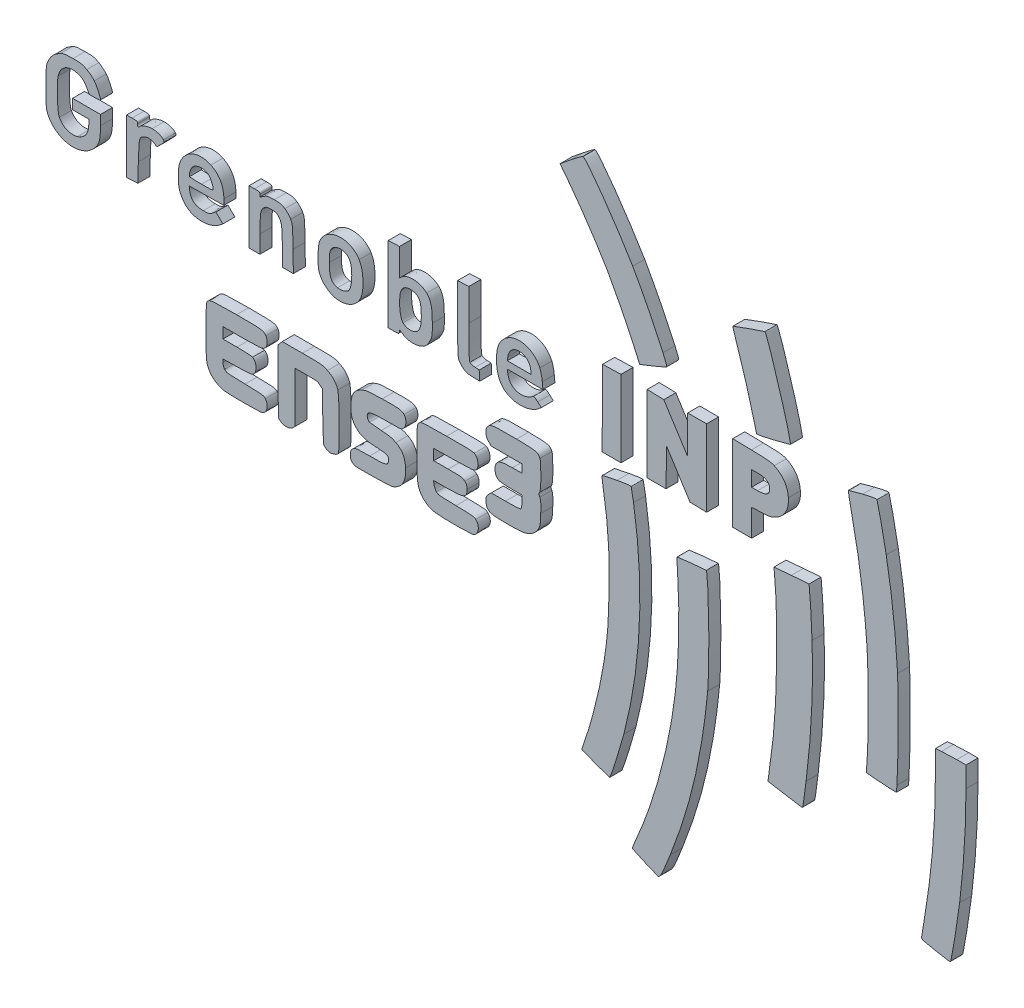
from build123d import *

# Parameters (mm, degrees)
BOSS_EXTRU_1_DEPTH    = 5
BOSS_EXTRU_1_2_DEPTH  = 5
BOSS_EXTRU_1_3_DEPTH  = 5
BOSS_EXTRU_1_4_DEPTH  = 5
BOSS_EXTRU_1_5_DEPTH  = 5
BOSS_EXTRU_1_6_DEPTH  = 5
BOSS_EXTRU_1_7_DEPTH  = 5
BOSS_EXTRU_1_8_DEPTH  = 5
BOSS_EXTRU_1_9_DEPTH  = 5
BOSS_EXTRU_1_10_DEPTH = 5
BOSS_EXTRU_1_11_DEPTH = 5
BOSS_EXTRU_1_12_DEPTH = 5
BOSS_EXTRU_1_13_DEPTH = 5
BOSS_EXTRU_1_14_DEPTH = 5
BOSS_EXTRU_1_15_DEPTH = 5
BOSS_EXTRU_1_16_DEPTH = 5
BOSS_EXTRU_1_17_DEPTH = 5
BOSS_EXTRU_1_18_DEPTH = 5
BOSS_EXTRU_1_19_DEPTH = 5
BOSS_EXTRU_1_20_DEPTH = 5
BOSS_EXTRU_1_21_DEPTH = 5
BOSS_EXTRU_1_22_DEPTH = 5
BOSS_EXTRU_1_23_DEPTH = 5


with BuildPart() as part:
    # Model → Boss.-Extru.1 (new body)
    with BuildSketch(Plane.XY):
        with BuildLine():
            Line((370.498256, 93.602025), (370.500131, 103.7665465))
            Line((370.500131, 103.7665465), (373.031381, 104.005609))
            add(Edge.make_bspline(
                [(373.031381, 104.005609), (374.423569, 104.137091), (377.2923, 104.2458675), (379.4064, 104.247334)],
                knots=[0, 0, 0, 0, 1, 1, 1, 1], degree=3))
            Line((379.4064, 104.247334), (383.25, 104.25))
            Line((383.25, 104.25), (383.25, 95.679979))
            add(Edge.make_bspline(
                [(383.25, 95.679979), (383.25, 81.8276325), (382.3465875, 67.311015), (380.6094, 53.25)],
                knots=[0, 0, 0, 0, 1, 1, 1, 1], degree=3))
            add(Edge.make_bspline(
                [(380.6094, 53.25), (379.78635, 46.5877535), (377.35485, 31.4443765), (376.9404375, 30.399585)],
                knots=[0, 0, 0, 0, 1, 1, 1, 1], degree=3))
            add(Edge.make_bspline(
                [(376.9404375, 30.399585), (376.7071875, 29.8114985), (376.2201375, 29.8524185), (370.6875, 30.9248885)],
                knots=[0, 0, 0, 0, 1, 1, 1, 1], degree=3))
            add(Edge.make_bspline(
                [(370.6875, 30.9248885), (365.301105, 31.969009), (364.694006, 32.1633525), (364.75113, 32.8252275)],
                knots=[0, 0, 0, 0, 1, 1, 1, 1], degree=3))
            add(Edge.make_bspline(
                [(364.75113, 32.8252275), (364.7861175, 33.2307265), (365.32917, 36.6), (365.9579025, 40.3125)],
                knots=[0, 0, 0, 0, 1, 1, 1, 1], degree=3))
            add(Edge.make_bspline(
                [(365.9579025, 40.3125), (369.01626, 58.371394), (370.4951925, 75.7294315), (370.498256, 93.602025)],
                knots=[0, 0, 0, 0, 1, 1, 1, 1], degree=3))
        make_face()
    extrude(amount=BOSS_EXTRU_1_DEPTH)


with BuildPart() as body_2:
    # Model → Boss.-Extru.1 2 (new body)
    with BuildSketch(Plane.XY):
        with BuildLine():
            Line((303.509539, 133.339766), (303.2850525, 135.6170325))
            Line((303.2850525, 135.6170325), (310.51746, 136.2460835))
            add(Edge.make_bspline(
                [(310.51746, 136.2460835), (314.495284, 136.5920585), (317.7958615, 136.8291375), (317.8520775, 136.772921)],
                knots=[0, 0, 0, 0, 1, 1, 1, 1], degree=3))
            add(Edge.make_bspline(
                [(317.8520775, 136.772921), (318.128865, 136.496134), (318.784729, 126.5555435), (319.152645, 117.0609375)],
                knots=[0, 0, 0, 0, 1, 1, 1, 1], degree=3))
            add(Edge.make_bspline(
                [(319.152645, 117.0609375), (319.784509, 100.7548125), (318.9010425, 82.25223), (316.6698115, 65.0625)],
                knots=[0, 0, 0, 0, 1, 1, 1, 1], degree=3))
            add(Edge.make_bspline(
                [(316.6698115, 65.0625), (315.355901, 54.9399375), (315.321499, 54.7451025), (314.8568735, 54.7953865)],
                knots=[0, 0, 0, 0, 1, 1, 1, 1], degree=3))
            add(Edge.make_bspline(
                [(314.8568735, 54.7953865), (314.626219, 54.8203615), (311.4, 55.344049), (307.6875, 55.959169)],
                knots=[0, 0, 0, 0, 1, 1, 1, 1], degree=3))
            add(Edge.make_bspline(
                [(307.6875, 55.959169), (303.975, 56.5742885), (300.891495, 57.1201835), (300.8352675, 57.1722675)],
                knots=[0, 0, 0, 0, 1, 1, 1, 1], degree=3))
            add(Edge.make_bspline(
                [(300.8352675, 57.1722675), (300.779036, 57.2243515), (300.983385, 58.9365865), (301.289374, 60.977235)],
                knots=[0, 0, 0, 0, 1, 1, 1, 1], degree=3))
            add(Edge.make_bspline(
                [(301.289374, 60.977235), (303.427399, 75.23586), (304.1690925, 85.0917485), (304.393369, 102.22419)],
                knots=[0, 0, 0, 0, 1, 1, 1, 1], degree=3))
            add(Edge.make_bspline(
                [(304.393369, 102.22419), (304.571775, 115.85289), (304.30398, 125.280791), (303.509539, 133.339766)],
                knots=[0, 0, 0, 0, 1, 1, 1, 1], degree=3))
        make_face()
    extrude(amount=BOSS_EXTRU_1_2_DEPTH)


with BuildPart() as body_3:
    # Model → Boss.-Extru.1 3 (new body)
    with BuildSketch(Plane.XY):
        with BuildLine():
            Line((354.509865, 82.59375), (354.2903625, 79.875))
            Line((354.2903625, 79.875), (351.9889275, 79.927065))
            add(Edge.make_bspline(
                [(351.9889275, 79.927065), (350.7231415, 79.9556775), (347.9220115, 80.1321225), (345.764194, 80.3191125)],
                knots=[0, 0, 0, 0, 1, 1, 1, 1], degree=3))
            add(Edge.make_bspline(
                [(345.764194, 80.3191125), (343.6063835, 80.5061065), (341.798666, 80.701335), (341.7470435, 80.7529535)],
                knots=[0, 0, 0, 0, 1, 1, 1, 1], degree=3))
            add(Edge.make_bspline(
                [(341.7470435, 80.7529535), (341.695425, 80.8045725), (341.84271, 82.9484625), (342.07434, 85.5171525)],
                knots=[0, 0, 0, 0, 1, 1, 1, 1], degree=3))
            add(Edge.make_bspline(
                [(342.07434, 85.5171525), (342.6552115, 91.9587225), (342.6463125, 118.350101), (342.06069, 126)],
                knots=[0, 0, 0, 0, 1, 1, 1, 1], degree=3))
            add(Edge.make_bspline(
                [(342.06069, 126), (340.7378965, 143.2795725), (338.8815865, 156.224445), (335.4000075, 172.44792)],
                knots=[0, 0, 0, 0, 1, 1, 1, 1], degree=3))
            add(Edge.make_bspline(
                [(335.4000075, 172.44792), (334.6758415, 175.8224025), (334.171054, 178.671056), (334.278259, 178.7782615)],
                knots=[0, 0, 0, 0, 1, 1, 1, 1], degree=3))
            add(Edge.make_bspline(
                [(334.278259, 178.7782615), (334.385464, 178.885466), (337.0526475, 179.608834), (340.2053365, 180.38574)],
                knots=[0, 0, 0, 0, 1, 1, 1, 1], degree=3))
            add(Edge.make_bspline(
                [(340.2053365, 180.38574), (344.3497615, 181.4070375), (346.0068375, 181.6776335), (346.1878425, 181.3626675)],
                knots=[0, 0, 0, 0, 1, 1, 1, 1], degree=3))
            add(Edge.make_bspline(
                [(346.1878425, 181.3626675), (346.51092, 180.8004785), (348.8174815, 170.051441), (350.042719, 163.3981575)],
                knots=[0, 0, 0, 0, 1, 1, 1, 1], degree=3))
            add(Edge.make_bspline(
                [(350.042719, 163.3981575), (352.2835725, 151.2299175), (353.9911465, 136.670906), (354.780874, 123)],
                knots=[0, 0, 0, 0, 1, 1, 1, 1], degree=3))
            add(Edge.make_bspline(
                [(354.780874, 123), (355.2110515, 115.553216), (355.033489, 89.0793185), (354.509865, 82.59375)],
                knots=[0, 0, 0, 0, 1, 1, 1, 1], degree=3))
        make_face()
    extrude(amount=BOSS_EXTRU_1_3_DEPTH)


with BuildPart() as body_4:
    # Model → Boss.-Extru.1 4 (new body)
    with BuildSketch(Plane.XY):
        with BuildLine():
            Line((81.7746525, 107.625), (73.875, 107.625))
            Line((73.875, 107.625), (73.875, 105.375))
            Line((73.875, 105.375), (73.875, 103.125))
            Line((73.875, 103.125), (79.7121525, 103.125))
            add(Edge.make_bspline(
                [(79.7121525, 103.125), (82.9225875, 103.125), (85.8525675, 102.9627), (86.2232215, 102.7643325)],
                knots=[0, 0, 0, 0, 1, 1, 1, 1], degree=3))
            add(Edge.make_bspline(
                [(86.2232215, 102.7643325), (87.915454, 101.8586775), (88.131154, 98.301259), (86.579089, 96.8952335)],
                knots=[0, 0, 0, 0, 1, 1, 1, 1], degree=3))
            add(Edge.make_bspline(
                [(86.579089, 96.8952335), (85.896619, 96.276979), (85.04415, 96.17148), (79.8364235, 96.0608025)],
                knots=[0, 0, 0, 0, 1, 1, 1, 1], degree=3))
            Line((79.8364235, 96.0608025), (73.875, 95.934105))
            Line((73.875, 95.934105), (73.875, 94.6960985))
            add(Edge.make_bspline(
                [(73.875, 94.6960985), (73.875, 94.0151925), (74.197346, 93.0597075), (74.591325, 92.5727925)],
                knots=[0, 0, 0, 0, 1, 1, 1, 1], degree=3))
            add(Edge.make_bspline(
                [(74.591325, 92.5727925), (75.292504, 91.706216), (75.4715925, 91.683536), (83.0629875, 91.5)],
                knots=[0, 0, 0, 0, 1, 1, 1, 1], degree=3))
            add(Edge.make_bspline(
                [(83.0629875, 91.5), (90.654559, 91.31646), (90.833441, 91.293806), (91.5341625, 90.4272075)],
                knots=[0, 0, 0, 0, 1, 1, 1, 1], degree=3))
            add(Edge.make_bspline(
                [(91.5341625, 90.4272075), (92.6248085, 89.0783775), (92.5000575, 86.615854), (91.283115, 85.4716165)],
                knots=[0, 0, 0, 0, 1, 1, 1, 1], degree=3))
            add(Edge.make_bspline(
                [(91.283115, 85.4716165), (90.335025, 84.580174), (90.176475, 84.5612065), (83.126865, 84.4958965)],
                knots=[0, 0, 0, 0, 1, 1, 1, 1], degree=3))
            add(Edge.make_bspline(
                [(83.126865, 84.4958965), (79.172715, 84.459259), (75.236134, 84.5743275), (74.3789065, 84.75159)],
                knots=[0, 0, 0, 0, 1, 1, 1, 1], degree=3))
            add(Edge.make_bspline(
                [(74.3789065, 84.75159), (70.5248215, 85.5485625), (67.909789, 88.0040065), (67.152, 91.5374475)],
                knots=[0, 0, 0, 0, 1, 1, 1, 1], degree=3))
            add(Edge.make_bspline(
                [(67.152, 91.5374475), (66.6060485, 94.083135), (66.617891, 111.7997665), (67.1663625, 113.003505)],
                knots=[0, 0, 0, 0, 1, 1, 1, 1], degree=3))
            add(Edge.make_bspline(
                [(67.1663625, 113.003505), (67.9040775, 114.6226125), (68.8067625, 114.75), (79.5423075, 114.75)],
                knots=[0, 0, 0, 0, 1, 1, 1, 1], degree=3))
            add(Edge.make_bspline(
                [(79.5423075, 114.75), (89.838064, 114.75), (90.7242865, 114.643635), (91.7693365, 113.2824975)],
                knots=[0, 0, 0, 0, 1, 1, 1, 1], degree=3))
            add(Edge.make_bspline(
                [(91.7693365, 113.2824975), (92.359275, 112.5141225), (92.359275, 109.8608775), (91.7693365, 109.0925025)],
                knots=[0, 0, 0, 0, 1, 1, 1, 1], degree=3))
            add(Edge.make_bspline(
                [(91.7693365, 109.0925025), (90.753896, 107.7699485), (89.7667125, 107.625), (81.7746525, 107.625)],
                knots=[0, 0, 0, 0, 1, 1, 1, 1], degree=3))
        make_face()
    extrude(amount=BOSS_EXTRU_1_4_DEPTH)


with BuildPart() as body_5:
    # Model → Boss.-Extru.1 5 (new body)
    with BuildSketch(Plane.XY):
        with BuildLine():
            Line((115.4135365, 96.501731), (115.3125, 105.8159625))
            Line((115.3125, 105.8159625), (114.26034, 106.720481))
            add(Edge.make_bspline(
                [(114.26034, 106.720481), (113.2701975, 107.5716825), (112.9330985, 107.625), (108.54159, 107.625)],
                knots=[0, 0, 0, 0, 1, 1, 1, 1], degree=3))
            Line((108.54159, 107.625), (103.875, 107.625))
            Line((103.875, 107.625), (103.875, 97.1079565))
            Line((103.875, 97.1079565), (103.875, 86.5909085))
            Line((103.875, 86.5909085), (102.9545435, 85.6704565))
            add(Edge.make_bspline(
                [(102.9545435, 85.6704565), (101.778476, 84.494385), (99.152835, 84.390041), (97.8227925, 85.46652)],
                knots=[0, 0, 0, 0, 1, 1, 1, 1], degree=3))
            Line((97.8227925, 85.46652), (96.9375, 86.183036))
            Line((96.9375, 86.183036), (96.830025, 99.3046535))
            Line((96.830025, 99.3046535), (96.722554, 112.4262675))
            Line((96.722554, 112.4262675), (97.641915, 113.4943835))
            Line((97.641915, 113.4943835), (98.56128, 114.5625))
            Line((98.56128, 114.5625), (106.93689, 114.5625))
            add(Edge.make_bspline(
                [(106.93689, 114.5625), (115.2932965, 114.5625), (115.3172625, 114.56025), (117.39021, 113.542095)],
                knots=[0, 0, 0, 0, 1, 1, 1, 1], degree=3))
            add(Edge.make_bspline(
                [(117.39021, 113.542095), (119.6543325, 112.4301415), (120.871744, 111.062096), (121.70907, 108.68886)],
                knots=[0, 0, 0, 0, 1, 1, 1, 1], degree=3))
            add(Edge.make_bspline(
                [(121.70907, 108.68886), (122.365399, 106.8286315), (122.5053565, 87.05283), (121.8705865, 85.866754)],
                knots=[0, 0, 0, 0, 1, 1, 1, 1], degree=3))
            add(Edge.make_bspline(
                [(121.8705865, 85.866754), (121.66191, 85.47684), (120.8603475, 84.982624), (120.0893365, 84.768499)],
                knots=[0, 0, 0, 0, 1, 1, 1, 1], degree=3))
            add(Edge.make_bspline(
                [(120.0893365, 84.768499), (118.393335, 84.2974875), (118.5815215, 84.287389), (117.106819, 84.9285825)],
                knots=[0, 0, 0, 0, 1, 1, 1, 1], degree=3))
            add(Edge.make_bspline(
                [(117.106819, 84.9285825), (116.389864, 85.2403085), (115.822785, 85.804391), (115.7078515, 86.320151)],
                knots=[0, 0, 0, 0, 1, 1, 1, 1], degree=3))
            add(Edge.make_bspline(
                [(115.7078515, 86.320151), (115.6015465, 86.7971925), (115.469104, 91.378905), (115.4135365, 96.501731)],
                knots=[0, 0, 0, 0, 1, 1, 1, 1], degree=3))
        make_face()
    extrude(amount=BOSS_EXTRU_1_5_DEPTH)


with BuildPart() as body_6:
    # Model → Boss.-Extru.1 6 (new body)
    with BuildSketch(Plane.XY):
        with BuildLine():
            Line((170.0498665, 107.6988075), (161.625, 107.5851185))
            Line((161.625, 107.5851185), (161.625, 105.3550575))
            Line((161.625, 105.3550575), (161.625, 103.125))
            Line((161.625, 103.125), (167.6420435, 103.125))
            add(Edge.make_bspline(
                [(167.6420435, 103.125), (173.530515, 103.125), (173.67876, 103.1053125), (174.5795435, 102.2045435)],
                knots=[0, 0, 0, 0, 1, 1, 1, 1], degree=3))
            add(Edge.make_bspline(
                [(174.5795435, 102.2045435), (175.276879, 101.5072125), (175.4971085, 100.89363), (175.488075, 99.6732935)],
                knots=[0, 0, 0, 0, 1, 1, 1, 1], degree=3))
            add(Edge.make_bspline(
                [(175.488075, 99.6732935), (175.4646525, 96.509805), (174.249791, 96), (166.73466, 96)],
                knots=[0, 0, 0, 0, 1, 1, 1, 1], degree=3))
            Line((166.73466, 96), (161.52687, 96))
            Line((161.52687, 96), (161.751435, 94.6161675))
            add(Edge.make_bspline(
                [(161.751435, 94.6161675), (161.874945, 93.85506), (162.32319, 92.8847475), (162.747536, 92.4599175)],
                knots=[0, 0, 0, 0, 1, 1, 1, 1], degree=3))
            add(Edge.make_bspline(
                [(162.747536, 92.4599175), (163.465571, 91.7410615), (164.0319935, 91.679404), (170.915786, 91.570729)],
                knots=[0, 0, 0, 0, 1, 1, 1, 1], degree=3))
            add(Edge.make_bspline(
                [(170.915786, 91.570729), (177.7166775, 91.4633665), (178.3771125, 91.3932825), (179.114629, 90.7007135)],
                knots=[0, 0, 0, 0, 1, 1, 1, 1], degree=3))
            add(Edge.make_bspline(
                [(179.114629, 90.7007135), (180.9302925, 88.9956975), (180.3485475, 85.5813225), (178.1093815, 84.800745)],
                knots=[0, 0, 0, 0, 1, 1, 1, 1], degree=3))
            add(Edge.make_bspline(
                [(178.1093815, 84.800745), (176.7309935, 84.3202385), (165.1078685, 84.2863875), (162.33861, 84.754815)],
                knots=[0, 0, 0, 0, 1, 1, 1, 1], degree=3))
            add(Edge.make_bspline(
                [(162.33861, 84.754815), (160.228335, 85.1117735), (158.7548325, 85.8474415), (157.363635, 87.238635)],
                knots=[0, 0, 0, 0, 1, 1, 1, 1], degree=3))
            add(Edge.make_bspline(
                [(157.363635, 87.238635), (154.8526725, 89.7496015), (154.4226525, 92.3258585), (154.5727275, 103.959056)],
                knots=[0, 0, 0, 0, 1, 1, 1, 1], degree=3))
            add(Edge.make_bspline(
                [(154.5727275, 103.959056), (154.6847325, 112.6409475), (154.708095, 112.876204), (155.541101, 113.709056)],
                knots=[0, 0, 0, 0, 1, 1, 1, 1], degree=3))
            add(Edge.make_bspline(
                [(155.541101, 113.709056), (156.383854, 114.551655), (156.529189, 114.5637335), (166.978601, 114.659614)],
                knots=[0, 0, 0, 0, 1, 1, 1, 1], degree=3))
            add(Edge.make_bspline(
                [(166.978601, 114.659614), (175.02201, 114.733421), (177.78753, 114.641051), (178.5, 114.2748375)],
                knots=[0, 0, 0, 0, 1, 1, 1, 1], degree=3))
            add(Edge.make_bspline(
                [(178.5, 114.2748375), (179.678089, 113.669276), (180.392265, 111.6177525), (179.9553375, 110.094266)],
                knots=[0, 0, 0, 0, 1, 1, 1, 1], degree=3))
            add(Edge.make_bspline(
                [(179.9553375, 110.094266), (179.307761, 107.836309), (179.2527185, 107.823), (170.0498665, 107.6988075)],
                knots=[0, 0, 0, 0, 1, 1, 1, 1], degree=3))
        make_face()
    extrude(amount=BOSS_EXTRU_1_6_DEPTH)


with BuildPart() as body_7:
    # Model → Boss.-Extru.1 7 (new body)
    with BuildSketch(Plane.XY):
        with BuildLine():
            Line((184.471155, 102.403845), (185.5673065, 103.5))
            Line((185.5673065, 103.5), (191.521155, 103.5))
            add(Edge.make_bspline(
                [(191.521155, 103.5), (195.6519225, 103.5), (197.61279, 103.63779), (197.925, 103.95)],
                knots=[0, 0, 0, 0, 1, 1, 1, 1], degree=3))
            add(Edge.make_bspline(
                [(197.925, 103.95), (198.179764, 104.2047635), (198.375, 105.4249985), (198.375, 106.7625)],
                knots=[0, 0, 0, 0, 1, 1, 1, 1], degree=3))
            Line((198.375, 106.7625), (198.375, 109.125))
            Line((198.375, 109.125), (194.080144, 109.125))
            add(Edge.make_bspline(
                [(194.080144, 109.125), (191.717974, 109.125), (189.3740815, 109.3123575), (188.871495, 109.541351)],
                knots=[0, 0, 0, 0, 1, 1, 1, 1], degree=3))
            add(Edge.make_bspline(
                [(188.871495, 109.541351), (187.269225, 110.271394), (186.62838, 112.874745), (187.55196, 114.901785)],
                knots=[0, 0, 0, 0, 1, 1, 1, 1], degree=3))
            add(Edge.make_bspline(
                [(187.55196, 114.901785), (188.2703475, 116.4784725), (189.972581, 117), (194.4004235, 117)],
                knots=[0, 0, 0, 0, 1, 1, 1, 1], degree=3))
            Line((194.4004235, 117), (198.375, 117))
            Line((198.375, 117), (198.375, 118.6875))
            Line((198.375, 118.6875), (198.375, 120.375))
            Line((198.375, 120.375), (191.971155, 120.375))
            Line((191.971155, 120.375), (185.5673065, 120.375))
            Line((185.5673065, 120.375), (184.471155, 121.471155))
            add(Edge.make_bspline(
                [(184.471155, 121.471155), (183.00801, 122.9343), (182.9086575, 125.567749), (184.265415, 126.9245065)],
                knots=[0, 0, 0, 0, 1, 1, 1, 1], degree=3))
            add(Edge.make_bspline(
                [(184.265415, 126.9245065), (185.490364, 128.149455), (187.1674765, 128.3276815), (196.12623, 128.184956)],
                knots=[0, 0, 0, 0, 1, 1, 1, 1], degree=3))
            add(Edge.make_bspline(
                [(196.12623, 128.184956), (204.33114, 128.0542385), (205.02405, 127.905375), (205.848315, 126.096315)],
                knots=[0, 0, 0, 0, 1, 1, 1, 1], degree=3))
            add(Edge.make_bspline(
                [(205.848315, 126.096315), (206.459209, 124.7555435), (206.3741475, 114.688129), (205.7446465, 113.827234)],
                knots=[0, 0, 0, 0, 1, 1, 1, 1], degree=3))
            add(Edge.make_bspline(
                [(205.7446465, 113.827234), (205.318654, 113.2446525), (205.3255875, 112.963144), (205.7888025, 112.034606)],
                knots=[0, 0, 0, 0, 1, 1, 1, 1], degree=3))
            add(Edge.make_bspline(
                [(205.7888025, 112.034606), (206.2100775, 111.19014), (206.3028825, 109.8688875), (206.1864825, 106.3727925)],
                knots=[0, 0, 0, 0, 1, 1, 1, 1], degree=3))
            add(Edge.make_bspline(
                [(206.1864825, 106.3727925), (206.0541115, 102.3969525), (205.9162875, 101.598364), (205.1110765, 100.14165)],
                knots=[0, 0, 0, 0, 1, 1, 1, 1], degree=3))
            add(Edge.make_bspline(
                [(205.1110765, 100.14165), (203.934034, 98.012254), (201.7385365, 96.4833335), (199.167566, 96.002655)],
                knots=[0, 0, 0, 0, 1, 1, 1, 1], degree=3))
            add(Edge.make_bspline(
                [(199.167566, 96.002655), (196.110686, 95.4311285), (186.813825, 95.545031), (185.3732775, 96.17166)],
                knots=[0, 0, 0, 0, 1, 1, 1, 1], degree=3))
            add(Edge.make_bspline(
                [(185.3732775, 96.17166), (183.8985115, 96.8131725), (183.375, 97.751726), (183.375, 99.7541925)],
                knots=[0, 0, 0, 0, 1, 1, 1, 1], degree=3))
            add(Edge.make_bspline(
                [(183.375, 99.7541925), (183.375, 100.9712175), (183.612416, 101.54511), (184.471155, 102.403845)],
                knots=[0, 0, 0, 0, 1, 1, 1, 1], degree=3))
        make_face()
    extrude(amount=BOSS_EXTRU_1_7_DEPTH)


with BuildPart() as body_8:
    # Model → Boss.-Extru.1 8 (new body)
    with BuildSketch(Plane.XY):
        with BuildLine():
            Line((20.53125, 163.5010835), (18.1875, 163.5022085))
            Line((18.1875, 163.5022085), (17.25, 165.2558025))
            add(Edge.make_bspline(
                [(17.25, 165.2558025), (16.129121, 167.352405), (14.9273015, 168.30258), (12.7884755, 168.7831425)],
                knots=[0, 0, 0, 0, 1, 1, 1, 1], degree=3))
            add(Edge.make_bspline(
                [(12.7884755, 168.7831425), (9.150577, 169.600526), (6.0431255, 167.508004), (5.254654, 163.709955)],
                knots=[0, 0, 0, 0, 1, 1, 1, 1], degree=3))
            add(Edge.make_bspline(
                [(5.254654, 163.709955), (4.5797245, 160.458836), (4.893112, 150.558641), (5.719867, 149.0134575)],
                knots=[0, 0, 0, 0, 1, 1, 1, 1], degree=3))
            add(Edge.make_bspline(
                [(5.719867, 149.0134575), (7.199301, 146.248429), (10.1992055, 145.0033685), (13.2941165, 145.8698885)],
                knots=[0, 0, 0, 0, 1, 1, 1, 1], degree=3))
            add(Edge.make_bspline(
                [(13.2941165, 145.8698885), (16.305325, 146.7129375), (18, 149.141254), (18, 152.612955)],
                knots=[0, 0, 0, 0, 1, 1, 1, 1], degree=3))
            Line((18, 152.612955), (18, 154.5))
            Line((18, 154.5), (14.625, 154.5))
            Line((14.625, 154.5), (11.25, 154.5))
            Line((11.25, 154.5), (11.25, 156.5625))
            Line((11.25, 156.5625), (11.25, 158.625))
            Line((11.25, 158.625), (17.0625, 158.625))
            Line((17.0625, 158.625), (22.875, 158.625))
            Line((22.875, 158.625), (22.875, 154.5680625))
            add(Edge.make_bspline(
                [(22.875, 154.5680625), (22.875, 149.04867), (22.2594395, 147.085526), (19.7382505, 144.5643375)],
                knots=[0, 0, 0, 0, 1, 1, 1, 1], degree=3))
            add(Edge.make_bspline(
                [(19.7382505, 144.5643375), (16.9865475, 141.812636), (12.8876685, 140.58441), (9.1002035, 141.3766615)],
                knots=[0, 0, 0, 0, 1, 1, 1, 1], degree=3))
            add(Edge.make_bspline(
                [(9.1002035, 141.3766615), (5.47001, 142.1360135), (2.4535505, 144.4224265), (1.084447, 147.4524375)],
                knots=[0, 0, 0, 0, 1, 1, 1, 1], degree=3))
            add(Edge.make_bspline(
                [(1.084447, 147.4524375), (0.23001, 149.34342), (0.1875, 149.81073), (0.1875, 157.3125)],
                knots=[0, 0, 0, 0, 1, 1, 1, 1], degree=3))
            add(Edge.make_bspline(
                [(0.1875, 157.3125), (0.1875, 165.179134), (0.188616, 165.1897725), (1.2379085, 167.3265375)],
                knots=[0, 0, 0, 0, 1, 1, 1, 1], degree=3))
            add(Edge.make_bspline(
                [(1.2379085, 167.3265375), (2.357268, 169.6059825), (3.6558345, 170.905665), (6.143824, 172.236675)],
                knots=[0, 0, 0, 0, 1, 1, 1, 1], degree=3))
            add(Edge.make_bspline(
                [(6.143824, 172.236675), (7.439466, 172.92981), (8.2900405, 173.0625), (11.4375, 173.0625)],
                knots=[0, 0, 0, 0, 1, 1, 1, 1], degree=3))
            add(Edge.make_bspline(
                [(11.4375, 173.0625), (14.888436, 173.0625), (15.346708, 172.9743075), (17.183831, 171.95664)],
                knots=[0, 0, 0, 0, 1, 1, 1, 1], degree=3))
            add(Edge.make_bspline(
                [(17.183831, 171.95664), (18.281813, 171.3484165), (19.6920875, 170.2044225), (20.317774, 169.414429)],
                knots=[0, 0, 0, 0, 1, 1, 1, 1], degree=3))
            add(Edge.make_bspline(
                [(20.317774, 169.414429), (21.34657, 168.115466), (22.875, 164.802199), (22.875, 163.870976)],
                knots=[0, 0, 0, 0, 1, 1, 1, 1], degree=3))
            add(Edge.make_bspline(
                [(22.875, 163.870976), (22.875, 163.665795), (21.8275395, 163.500484), (20.53125, 163.5010835)],
                knots=[0, 0, 0, 0, 1, 1, 1, 1], degree=3))
        make_face()
    extrude(amount=BOSS_EXTRU_1_8_DEPTH)


with BuildPart() as body_9:
    # Model → Boss.-Extru.1 9 (new body)
    with BuildSketch(Plane.XY):
        with BuildLine():
            Line((74.25, 153.8787935), (74.25, 151.5161965))
            Line((74.25, 151.5161965), (67.03125, 151.414346))
            Line((67.03125, 151.414346), (59.8125, 151.3125))
            Line((59.8125, 151.3125), (59.939824, 150.1875))
            add(Edge.make_bspline(
                [(59.939824, 150.1875), (60.3202615, 146.8260865), (62.07813, 145.32843), (65.65419, 145.3190025)],
                knots=[0, 0, 0, 0, 1, 1, 1, 1], degree=3))
            add(Edge.make_bspline(
                [(65.65419, 145.3190025), (67.7973485, 145.31334), (68.3057965, 145.4535415), (69.5307265, 146.3878425)],
                knots=[0, 0, 0, 0, 1, 1, 1, 1], degree=3))
            Line((69.5307265, 146.3878425), (70.9405725, 147.463181))
            Line((70.9405725, 147.463181), (72.3883575, 146.0494575))
            Line((72.3883575, 146.0494575), (73.8361465, 144.63573))
            Line((73.8361465, 144.63573), (72.305974, 143.4248625))
            add(Edge.make_bspline(
                [(72.305974, 143.4248625), (69.932434, 141.5466115), (65.9642025, 140.703664), (62.69409, 141.383066)],
                knots=[0, 0, 0, 0, 1, 1, 1, 1], degree=3))
            add(Edge.make_bspline(
                [(62.69409, 141.383066), (59.669644, 142.011439), (57.574125, 143.7617775), (56.1883425, 146.81718)],
                knots=[0, 0, 0, 0, 1, 1, 1, 1], degree=3))
            add(Edge.make_bspline(
                [(56.1883425, 146.81718), (55.4787415, 148.381725), (55.340685, 149.331259), (55.3439215, 152.6250075)],
                knots=[0, 0, 0, 0, 1, 1, 1, 1], degree=3))
            add(Edge.make_bspline(
                [(55.3439215, 152.6250075), (55.347296, 155.922079), (55.4890615, 156.8813215), (56.21637, 158.5226515)],
                knots=[0, 0, 0, 0, 1, 1, 1, 1], degree=3))
            add(Edge.make_bspline(
                [(56.21637, 158.5226515), (58.438054, 163.5363565), (63.9339035, 165.641295), (68.8390725, 163.357219)],
                knots=[0, 0, 0, 0, 1, 1, 1, 1], degree=3))
            add(Edge.make_bspline(
                [(68.8390725, 163.357219), (72.3173625, 161.7375565), (74.25, 158.352124), (74.25, 153.8787935)],
                knots=[0, 0, 0, 0, 1, 1, 1, 1], degree=3))
        make_face()
        with BuildLine():
            add(Edge.make_bspline(
                [(69.75, 155.24241), (69.75, 156.520515), (68.598896, 158.9308465), (67.7105285, 159.512929)],
                knots=[0, 0, 0, 0, 1, 1, 1, 1], degree=3))
            add(Edge.make_bspline(
                [(67.7105285, 159.512929), (65.511004, 160.95411), (62.2229475, 160.451966), (60.929085, 158.4772875)],
                knots=[0, 0, 0, 0, 1, 1, 1, 1], degree=3))
            add(Edge.make_bspline(
                [(60.929085, 158.4772875), (60.2343675, 157.417016), (59.5948575, 155.030141), (59.918726, 154.7062725)],
                knots=[0, 0, 0, 0, 1, 1, 1, 1], degree=3))
            add(Edge.make_bspline(
                [(59.918726, 154.7062725), (60.032175, 154.592824), (62.2906235, 154.5), (64.937501, 154.5)],
                knots=[0, 0, 0, 0, 1, 1, 1, 1], degree=3))
            add(Edge.make_bspline(
                [(64.937501, 154.5), (69.483604, 154.5), (69.75, 154.5410965), (69.75, 155.24241)],
                knots=[0, 0, 0, 0, 1, 1, 1, 1], degree=3))
        make_face(mode=Mode.SUBTRACT)
    extrude(amount=BOSS_EXTRU_1_9_DEPTH)


with BuildPart() as body_10:
    # Model → Boss.-Extru.1 10 (new body)
    with BuildSketch(Plane.XY):
        with BuildLine():
            Line((148.4879025, 142.5086135), (147.4288315, 143.262739))
            Line((147.4288315, 143.262739), (147.3081675, 142.4126175))
            add(Edge.make_bspline(
                [(147.3081675, 142.4126175), (147.198075, 141.6369935), (146.9903435, 141.5625), (144.9375, 141.5625)],
                knots=[0, 0, 0, 0, 1, 1, 1, 1], degree=3))
            Line((144.9375, 141.5625), (142.6875, 141.5625))
            Line((142.6875, 141.5625), (142.6875, 157.3125))
            Line((142.6875, 157.3125), (142.6875, 173.0625))
            Line((142.6875, 173.0625), (145.03125, 173.174145))
            Line((145.03125, 173.174145), (147.375, 173.2857865))
            Line((147.375, 173.2857865), (147.375, 167.577525))
            Line((147.375, 167.577525), (147.375, 161.869264))
            Line((147.375, 161.869264), (148.21875, 162.659651))
            add(Edge.make_bspline(
                [(148.21875, 162.659651), (150.7447615, 165.025909), (155.9475075, 164.7518325), (158.7087265, 162.107051)],
                knots=[0, 0, 0, 0, 1, 1, 1, 1], degree=3))
            add(Edge.make_bspline(
                [(158.7087265, 162.107051), (160.455851, 160.4336025), (161.0625, 157.9414165), (161.0625, 152.4375)],
                knots=[0, 0, 0, 0, 1, 1, 1, 1], degree=3))
            add(Edge.make_bspline(
                [(161.0625, 152.4375), (161.0625, 147.770835), (161.014421, 147.466346), (159.9375, 145.3125)],
                knots=[0, 0, 0, 0, 1, 1, 1, 1], degree=3))
            add(Edge.make_bspline(
                [(159.9375, 145.3125), (159.087544, 143.612591), (158.4457725, 142.863829), (157.3125, 142.24989)],
                knots=[0, 0, 0, 0, 1, 1, 1, 1], degree=3))
            add(Edge.make_bspline(
                [(157.3125, 142.24989), (155.4959585, 141.265796), (152.9452425, 140.923181), (150.992235, 141.4009385)],
                knots=[0, 0, 0, 0, 1, 1, 1, 1], degree=3))
            add(Edge.make_bspline(
                [(150.992235, 141.4009385), (150.19734, 141.595395), (149.07039, 142.093849), (148.4879025, 142.5086135)],
                knots=[0, 0, 0, 0, 1, 1, 1, 1], degree=3))
        make_face()
        with BuildLine():
            add(Edge.make_bspline(
                [(154.7703675, 146.355495), (155.9794275, 147.451215), (156.45, 149.2602335), (156.45, 152.8125)],
                knots=[0, 0, 0, 0, 1, 1, 1, 1], degree=3))
            add(Edge.make_bspline(
                [(156.45, 152.8125), (156.45, 157.871115), (155.5230785, 159.6338475), (152.661184, 160.017705)],
                knots=[0, 0, 0, 0, 1, 1, 1, 1], degree=3))
            add(Edge.make_bspline(
                [(152.661184, 160.017705), (150.668074, 160.2850385), (148.99149, 159.5605085), (148.2314965, 158.103431)],
                knots=[0, 0, 0, 0, 1, 1, 1, 1], degree=3))
            add(Edge.make_bspline(
                [(148.2314965, 158.103431), (146.878294, 155.509039), (147.2850715, 147.8763635), (148.852121, 146.4582075)],
                knots=[0, 0, 0, 0, 1, 1, 1, 1], degree=3))
            add(Edge.make_bspline(
                [(148.852121, 146.4582075), (150.4218375, 145.0376325), (153.2617985, 144.9883465), (154.7703675, 146.355495)],
                knots=[0, 0, 0, 0, 1, 1, 1, 1], degree=3))
        make_face(mode=Mode.SUBTRACT)
    extrude(amount=BOSS_EXTRU_1_10_DEPTH)


with BuildPart() as body_11:
    # Model → Boss.-Extru.1 11 (new body)
    with BuildSketch(Plane.XY):
        with BuildLine():
            Line((206.8299485, 154.21875), (207.0969075, 151.5))
            Line((207.0969075, 151.5), (199.6865775, 151.5))
            Line((199.6865775, 151.5), (192.2762475, 151.5))
            Line((192.2762475, 151.5), (192.4856585, 149.9387175))
            add(Edge.make_bspline(
                [(192.4856585, 149.9387175), (193.1108285, 145.277745), (198.37752, 143.643709), (202.6875, 146.7735115)],
                knots=[0, 0, 0, 0, 1, 1, 1, 1], degree=3))
            add(Edge.make_bspline(
                [(202.6875, 146.7735115), (203.37345, 147.2716315), (203.5656, 147.205796), (204.9375, 146.0026425)],
                knots=[0, 0, 0, 0, 1, 1, 1, 1], degree=3))
            Line((204.9375, 146.0026425), (206.4375, 144.6871425))
            Line((206.4375, 144.6871425), (205.3125, 143.7470025))
            add(Edge.make_bspline(
                [(205.3125, 143.7470025), (202.83063, 141.67296), (198.822761, 140.711891), (195.4752035, 141.388069)],
                knots=[0, 0, 0, 0, 1, 1, 1, 1], degree=3))
            add(Edge.make_bspline(
                [(195.4752035, 141.388069), (190.2019275, 142.4532225), (187.7662125, 146.0664375), (187.7636435, 152.8276315)],
                knots=[0, 0, 0, 0, 1, 1, 1, 1], degree=3))
            add(Edge.make_bspline(
                [(187.7636435, 152.8276315), (187.7621435, 156.942926), (188.6258775, 159.4136815), (190.8352575, 161.6134915)],
                knots=[0, 0, 0, 0, 1, 1, 1, 1], degree=3))
            add(Edge.make_bspline(
                [(190.8352575, 161.6134915), (195.437951, 166.1962615), (203.2456985, 164.660186), (205.82082, 158.665275)],
                knots=[0, 0, 0, 0, 1, 1, 1, 1], degree=3))
            add(Edge.make_bspline(
                [(205.82082, 158.665275), (206.229011, 157.714999), (206.6831175, 155.7140625), (206.8299485, 154.21875)],
                knots=[0, 0, 0, 0, 1, 1, 1, 1], degree=3))
        make_face()
        with BuildLine():
            Line((192.4856585, 156.0612825), (192.2762475, 154.5))
            Line((192.2762475, 154.5), (197.25, 154.5))
            Line((197.25, 154.5), (202.2237525, 154.5))
            Line((202.2237525, 154.5), (202.014341, 156.0612825))
            add(Edge.make_bspline(
                [(202.014341, 156.0612825), (201.7354875, 158.1402785), (200.704241, 159.444285), (198.8097785, 160.113439)],
                knots=[0, 0, 0, 0, 1, 1, 1, 1], degree=3))
            add(Edge.make_bspline(
                [(198.8097785, 160.113439), (195.807041, 161.1740475), (192.9236175, 159.326505), (192.4856585, 156.0612825)],
                knots=[0, 0, 0, 0, 1, 1, 1, 1], degree=3))
        make_face(mode=Mode.SUBTRACT)
    extrude(amount=BOSS_EXTRU_1_11_DEPTH)


with BuildPart() as body_12:
    # Model → Boss.-Extru.1 12 (new body)
    with BuildSketch(Plane.XY):
        with BuildLine():
            Line((33.75, 152.607105), (33.75, 163.875))
            Line((33.75, 163.875), (36, 163.875))
            add(Edge.make_bspline(
                [(36, 163.875), (38.1499985, 163.875), (38.25, 163.833334), (38.25, 162.9375)],
                knots=[0, 0, 0, 0, 1, 1, 1, 1], degree=3))
            add(Edge.make_bspline(
                [(38.25, 162.9375), (38.25, 161.9680615), (38.7633115, 161.6886485), (39.2116315, 162.414049)],
                knots=[0, 0, 0, 0, 1, 1, 1, 1], degree=3))
            add(Edge.make_bspline(
                [(39.2116315, 162.414049), (39.7049515, 163.212255), (42.5795775, 164.233609), (44.355795, 164.241765)],
                knots=[0, 0, 0, 0, 1, 1, 1, 1], degree=3))
            add(Edge.make_bspline(
                [(44.355795, 164.241765), (46.3420015, 164.2508775), (48.2818275, 163.579609), (49.0919025, 162.602835)],
                knots=[0, 0, 0, 0, 1, 1, 1, 1], degree=3))
            add(Edge.make_bspline(
                [(49.0919025, 162.602835), (49.563274, 162.0344625), (49.4452465, 161.785099), (48.0151465, 160.3279315)],
                knots=[0, 0, 0, 0, 1, 1, 1, 1], degree=3))
            Line((48.0151465, 160.3279315), (46.4089835, 158.691375))
            Line((46.4089835, 158.691375), (45.2357435, 159.406785))
            add(Edge.make_bspline(
                [(45.2357435, 159.406785), (43.8208015, 160.2695775), (42.3417525, 160.3209865), (40.8674925, 159.5586185)],
                knots=[0, 0, 0, 0, 1, 1, 1, 1], degree=3))
            add(Edge.make_bspline(
                [(40.8674925, 159.5586185), (38.9703825, 158.577585), (38.8272375, 157.9315315), (38.625, 149.4375)],
                knots=[0, 0, 0, 0, 1, 1, 1, 1], degree=3))
            Line((38.625, 149.4375), (38.4375, 141.5625))
            Line((38.4375, 141.5625), (36.09375, 141.450855))
            Line((36.09375, 141.450855), (33.75, 141.3392135))
            Line((33.75, 141.3392135), (33.75, 152.607105))
        make_face()
    extrude(amount=BOSS_EXTRU_1_12_DEPTH)


with BuildPart() as body_13:
    # Model → Boss.-Extru.1 13 (new body)
    with BuildSketch(Plane.XY):
        with BuildLine():
            Line((84.75, 152.625), (84.75, 163.875))
            Line((84.75, 163.875), (87, 163.875))
            add(Edge.make_bspline(
                [(87, 163.875), (89.153385, 163.875), (89.25, 163.834515), (89.25, 162.9321785)],
                knots=[0, 0, 0, 0, 1, 1, 1, 1], degree=3))
            Line((89.25, 162.9321785), (89.25, 161.9893575))
            Line((89.25, 161.9893575), (90.81606, 163.0259285))
            add(Edge.make_bspline(
                [(90.81606, 163.0259285), (92.1834485, 163.930999), (92.7457125, 164.0625), (95.2481365, 164.0625)],
                knots=[0, 0, 0, 0, 1, 1, 1, 1], degree=3))
            add(Edge.make_bspline(
                [(95.2481365, 164.0625), (97.7468285, 164.0625), (98.3141585, 163.930275), (99.67467, 163.03083)],
                knots=[0, 0, 0, 0, 1, 1, 1, 1], degree=3))
            add(Edge.make_bspline(
                [(99.67467, 163.03083), (100.5336035, 162.4629825), (101.617849, 161.2828275), (102.0863435, 160.40583)],
                knots=[0, 0, 0, 0, 1, 1, 1, 1], degree=3))
            add(Edge.make_bspline(
                [(102.0863435, 160.40583), (102.8892635, 158.902796), (102.9442275, 158.318404), (103.056184, 150.09375)],
                knots=[0, 0, 0, 0, 1, 1, 1, 1], degree=3))
            Line((103.056184, 150.09375), (103.174871, 141.375))
            Line((103.174871, 141.375), (100.899934, 141.375))
            Line((100.899934, 141.375), (98.625, 141.375))
            Line((98.625, 141.375), (98.6086875, 148.03125))
            add(Edge.make_bspline(
                [(98.6086875, 148.03125), (98.5895625, 155.825104), (98.3239315, 157.5965435), (96.9715465, 158.9489285)],
                knots=[0, 0, 0, 0, 1, 1, 1, 1], degree=3))
            add(Edge.make_bspline(
                [(96.9715465, 158.9489285), (96.1488, 159.771671), (95.6450365, 159.9375), (93.9683665, 159.9375)],
                knots=[0, 0, 0, 0, 1, 1, 1, 1], degree=3))
            add(Edge.make_bspline(
                [(93.9683665, 159.9375), (92.484135, 159.9375), (91.73232, 159.740051), (91.1126325, 159.1875)],
                knots=[0, 0, 0, 0, 1, 1, 1, 1], degree=3))
            add(Edge.make_bspline(
                [(91.1126325, 159.1875), (89.4689025, 157.721865), (89.25, 156.48927), (89.25, 148.699545)],
                knots=[0, 0, 0, 0, 1, 1, 1, 1], degree=3))
            Line((89.25, 148.699545), (89.25, 141.375))
            Line((89.25, 141.375), (87, 141.375))
            Line((87, 141.375), (84.75, 141.375))
            Line((84.75, 141.375), (84.75, 152.625))
        make_face()
    extrude(amount=BOSS_EXTRU_1_13_DEPTH)


with BuildPart() as body_14:
    # Model → Boss.-Extru.1 14 (new body)
    with BuildSketch(Plane.XY):
        with BuildLine():
            Line((171.5625, 159.375), (171.5625, 173.0625))
            Line((171.5625, 173.0625), (173.90625, 173.174145))
            Line((173.90625, 173.174145), (176.25, 173.2857865))
            Line((176.25, 173.2857865), (176.25, 160.027069))
            add(Edge.make_bspline(
                [(176.25, 160.027069), (176.25, 149.998935), (176.364214, 146.618115), (176.71875, 146.151769)],
                knots=[0, 0, 0, 0, 1, 1, 1, 1], degree=3))
            add(Edge.make_bspline(
                [(176.71875, 146.151769), (177.001755, 145.7795135), (177.856185, 145.4910675), (178.875, 145.423845)],
                knots=[0, 0, 0, 0, 1, 1, 1, 1], degree=3))
            Line((178.875, 145.423845), (180.5625, 145.3125))
            Line((180.5625, 145.3125), (180.6758475, 143.34375))
            Line((180.6758475, 143.34375), (180.789195, 141.375))
            Line((180.789195, 141.375), (178.6133475, 141.4185))
            add(Edge.make_bspline(
                [(178.6133475, 141.4185), (177.4166325, 141.442425), (176.1, 141.546506), (175.6875, 141.649785)],
                knots=[0, 0, 0, 0, 1, 1, 1, 1], degree=3))
            add(Edge.make_bspline(
                [(175.6875, 141.649785), (174.458655, 141.957465), (172.9073475, 143.2293225), (172.213091, 144.498315)],
                knots=[0, 0, 0, 0, 1, 1, 1, 1], degree=3))
            add(Edge.make_bspline(
                [(172.213091, 144.498315), (171.629239, 145.5655085), (171.5625, 147.0915975), (171.5625, 159.375)],
                knots=[0, 0, 0, 0, 1, 1, 1, 1], degree=3))
        make_face()
    extrude(amount=BOSS_EXTRU_1_14_DEPTH)


with BuildPart() as body_15:
    # Model → Boss.-Extru.1 15 (new body)
    with BuildSketch(Plane.XY):
        Polygon((231.8396815, 157.21875), (231.9375, 173.0625), (235.78125, 173.1693675), (239.625, 173.276239), (239.625, 157.3256175), (239.625, 141.375), (235.6834315, 141.375), (231.741859, 141.375), align=None)
    extrude(amount=BOSS_EXTRU_1_15_DEPTH)


with BuildPart() as body_16:
    # Model → Boss.-Extru.1 16 (new body)
    with BuildSketch(Plane.XY):
        Polygon((250.5, 157.3265735), (250.5, 173.2781435), (253.96776, 173.1703235), (257.43552, 173.0625), (262.31151, 165.41412), (267.1875, 157.76574), (267.288859, 165.50787), (267.3902175, 173.25), (271.320109, 173.25), (275.25, 173.25), (275.25, 157.2984265), (275.25, 141.346856), (271.79235, 141.4546765), (268.3347, 141.5625), (263.4486, 149.2382965), (258.5625, 156.9140925), (258.461141, 149.1445465), (258.3597825, 141.375), (254.429891, 141.375), (250.5, 141.375), align=None)
    extrude(amount=BOSS_EXTRU_1_16_DEPTH)


with BuildPart() as body_17:
    # Model → Boss.-Extru.1 17 (new body)
    with BuildSketch(Plane.XY):
        with BuildLine():
            Line((286.125, 157.3503935), (286.125, 173.325776))
            Line((286.125, 173.325776), (293.90625, 173.1680325))
            add(Edge.make_bspline(
                [(293.90625, 173.1680325), (300.7934435, 173.028416), (301.88697, 172.9201015), (303.4235475, 172.2253465)],
                knots=[0, 0, 0, 0, 1, 1, 1, 1], degree=3))
            add(Edge.make_bspline(
                [(303.4235475, 172.2253465), (306.9407965, 170.635035), (309.036, 167.5664325), (309.3028575, 163.6146)],
                knots=[0, 0, 0, 0, 1, 1, 1, 1], degree=3))
            add(Edge.make_bspline(
                [(309.3028575, 163.6146), (309.596809, 159.261491), (307.60671, 155.716245), (303.832669, 153.8697785)],
                knots=[0, 0, 0, 0, 1, 1, 1, 1], degree=3))
            add(Edge.make_bspline(
                [(303.832669, 153.8697785), (302.0151415, 152.980545), (301.12347, 152.80362), (297.8484525, 152.682386)],
                knots=[0, 0, 0, 0, 1, 1, 1, 1], degree=3))
            Line((297.8484525, 152.682386), (294, 152.539935))
            Line((294, 152.539935), (294, 146.9574675))
            Line((294, 146.9574675), (294, 141.375))
            Line((294, 141.375), (290.0625, 141.375))
            Line((290.0625, 141.375), (286.125, 141.375))
            Line((286.125, 141.375), (286.125, 157.3503935))
        make_face()
        with BuildLine():
            Line((296.4621525, 166.125), (294, 166.125))
            Line((294, 166.125), (294, 162.9375))
            Line((294, 162.9375), (294, 159.75))
            Line((294, 159.75), (296.4561225, 159.75))
            add(Edge.make_bspline(
                [(296.4561225, 159.75), (297.8782985, 159.75), (299.3588625, 159.980955), (299.97318, 160.298629)],
                knots=[0, 0, 0, 0, 1, 1, 1, 1], degree=3))
            add(Edge.make_bspline(
                [(299.97318, 160.298629), (301.14594, 160.9050825), (301.505955, 161.561779), (301.488075, 163.061914)],
                knots=[0, 0, 0, 0, 1, 1, 1, 1], degree=3))
            add(Edge.make_bspline(
                [(301.488075, 163.061914), (301.4629725, 165.1679925), (299.892705, 166.125), (296.4621525, 166.125)],
                knots=[0, 0, 0, 0, 1, 1, 1, 1], degree=3))
        make_face(mode=Mode.SUBTRACT)
    extrude(amount=BOSS_EXTRU_1_17_DEPTH)


with BuildPart() as body_18:
    # Model → Boss.-Extru.1 18 (new body)
    with BuildSketch(Plane.XY):
        with BuildLine():
            Line((218.165209, 231.4251485), (214.22367, 236.5377965))
            Line((214.22367, 236.5377965), (218.7289425, 240.194666))
            add(Edge.make_bspline(
                [(218.7289425, 240.194666), (221.206841, 242.205944), (223.489924, 243.8708775), (223.8024565, 243.8945175)],
                knots=[0, 0, 0, 0, 1, 1, 1, 1], degree=3))
            add(Edge.make_bspline(
                [(223.8024565, 243.8945175), (225.0921715, 243.992072), (238.035791, 225.70529), (244.4755575, 214.6875)],
                knots=[0, 0, 0, 0, 1, 1, 1, 1], degree=3))
            add(Edge.make_bspline(
                [(244.4755575, 214.6875), (248.035121, 208.59745), (254.44851, 195.9488175), (257.0839275, 189.8209835)],
                knots=[0, 0, 0, 0, 1, 1, 1, 1], degree=3))
            add(Edge.make_bspline(
                [(257.0839275, 189.8209835), (258.610785, 186.27075), (258.8188085, 185.523191), (258.360296, 185.2341635)],
                knots=[0, 0, 0, 0, 1, 1, 1, 1], degree=3))
            add(Edge.make_bspline(
                [(258.360296, 185.2341635), (257.8716975, 184.92618), (247.6547325, 180.75), (247.38984, 180.75)],
                knots=[0, 0, 0, 0, 1, 1, 1, 1], degree=3))
            add(Edge.make_bspline(
                [(247.38984, 180.75), (247.3308975, 180.75), (246.633274, 182.3109375), (245.839564, 184.21875)],
                knots=[0, 0, 0, 0, 1, 1, 1, 1], degree=3))
            add(Edge.make_bspline(
                [(245.839564, 184.21875), (243.7642875, 189.207015), (237.196725, 202.274164), (234.0127385, 207.75)],
                knots=[0, 0, 0, 0, 1, 1, 1, 1], degree=3))
            add(Edge.make_bspline(
                [(234.0127385, 207.75), (230.056455, 214.554032), (222.705619, 225.5356855), (218.165209, 231.4251485)],
                knots=[0, 0, 0, 0, 1, 1, 1, 1], degree=3))
        make_face()
    extrude(amount=BOSS_EXTRU_1_18_DEPTH)


with BuildPart() as body_19:
    # Model → Boss.-Extru.1 19 (new body)
    with BuildSketch(Plane.XY):
        with BuildLine():
            add(Edge.make_bspline(
                [(249.5625, 2.24961), (246.88125, 3.479475), (244.5530475, 4.533754), (244.388715, 4.592456)],
                knots=[0, 0, 0, 0, 1, 1, 1, 1], degree=3))
            add(Edge.make_bspline(
                [(244.388715, 4.592456), (244.2243865, 4.6511585), (244.845825, 6.4040475), (245.7696975, 8.487765)],
                knots=[0, 0, 0, 0, 1, 1, 1, 1], degree=3))
            add(Edge.make_bspline(
                [(245.7696975, 8.487765), (253.7190675, 26.41695), (259.9566225, 49.7656685), (262.286025, 70.3125)],
                knots=[0, 0, 0, 0, 1, 1, 1, 1], degree=3))
            add(Edge.make_bspline(
                [(262.286025, 70.3125), (263.7234675, 82.991685), (264.09261, 99.870195), (263.2107975, 112.5965435)],
                knots=[0, 0, 0, 0, 1, 1, 1, 1], degree=3))
            add(Edge.make_bspline(
                [(263.2107975, 112.5965435), (262.97061, 116.062946), (262.8546115, 118.97961), (262.953019, 119.0780175)],
                knots=[0, 0, 0, 0, 1, 1, 1, 1], degree=3))
            add(Edge.make_bspline(
                [(262.953019, 119.0780175), (263.19654, 119.3215425), (274.8687375, 120.506261), (275.067379, 120.30762)],
                knots=[0, 0, 0, 0, 1, 1, 1, 1], degree=3))
            add(Edge.make_bspline(
                [(275.067379, 120.30762), (276.13419, 119.2408125), (276.618375, 86.4395175), (275.70573, 77.0625)],
                knots=[0, 0, 0, 0, 1, 1, 1, 1], degree=3))
            add(Edge.make_bspline(
                [(275.70573, 77.0625), (273.251299, 51.844316), (268.591504, 31.8715685), (260.1261975, 10.285755)],
                knots=[0, 0, 0, 0, 1, 1, 1, 1], degree=3))
            add(Edge.make_bspline(
                [(260.1261975, 10.285755), (256.95351, 2.195666), (255.881404, -0.001005), (255.1094325, 0.006746)],
                knots=[0, 0, 0, 0, 1, 1, 1, 1], degree=3))
            add(Edge.make_bspline(
                [(255.1094325, 0.006746), (254.73987, 0.010496), (252.24375, 1.019745), (249.5625, 2.24961)],
                knots=[0, 0, 0, 0, 1, 1, 1, 1], degree=3))
        make_face()
    extrude(amount=BOSS_EXTRU_1_19_DEPTH)


with BuildPart() as body_20:
    # Model → Boss.-Extru.1 20 (new body)
    with BuildSketch(Plane.XY):
        with BuildLine():
            add(Edge.make_bspline(
                [(228.9375, 27.633994), (225.84375, 28.7842575), (223.2808315, 29.748525), (223.2421275, 29.776815)],
                knots=[0, 0, 0, 0, 1, 1, 1, 1], degree=3))
            add(Edge.make_bspline(
                [(223.2421275, 29.776815), (223.20342, 29.80509), (223.6806035, 31.2590775), (224.30253, 33.007871)],
                knots=[0, 0, 0, 0, 1, 1, 1, 1], degree=3))
            add(Edge.make_bspline(
                [(224.30253, 33.007871), (227.4976835, 41.9923125), (230.976206, 55.967021), (232.512611, 65.991266)],
                knots=[0, 0, 0, 0, 1, 1, 1, 1], degree=3))
            add(Edge.make_bspline(
                [(232.512611, 65.991266), (234.049121, 76.0161935), (234.4430585, 80.90826), (234.642476, 92.4408825)],
                knots=[0, 0, 0, 0, 1, 1, 1, 1], degree=3))
            add(Edge.make_bspline(
                [(234.642476, 92.4408825), (234.894506, 107.0163635), (234.225015, 116.81409), (232.148505, 128.939051)],
                knots=[0, 0, 0, 0, 1, 1, 1, 1], degree=3))
            add(Edge.make_bspline(
                [(232.148505, 128.939051), (231.6792225, 131.679236), (231.605955, 132.8621435), (231.898556, 132.9743735)],
                knots=[0, 0, 0, 0, 1, 1, 1, 1], degree=3))
            add(Edge.make_bspline(
                [(231.898556, 132.9743735), (232.126226, 133.0617), (234.84375, 133.619546), (237.9375, 134.21403)],
                knots=[0, 0, 0, 0, 1, 1, 1, 1], degree=3))
            add(Edge.make_bspline(
                [(237.9375, 134.21403), (241.6270425, 134.923001), (243.645135, 135.1626635), (243.802661, 134.910555)],
                knots=[0, 0, 0, 0, 1, 1, 1, 1], degree=3))
            add(Edge.make_bspline(
                [(243.802661, 134.910555), (243.934751, 134.69916), (244.3940135, 132.312491), (244.8232425, 129.606851)],
                knots=[0, 0, 0, 0, 1, 1, 1, 1], degree=3))
            add(Edge.make_bspline(
                [(244.8232425, 129.606851), (249.3959925, 100.782611), (248.031041, 71.899781), (240.7825835, 44.105351)],
                knots=[0, 0, 0, 0, 1, 1, 1, 1], degree=3))
            add(Edge.make_bspline(
                [(240.7825835, 44.105351), (239.05683, 37.487891), (235.2124575, 25.4903925), (234.8276775, 25.5213)],
                knots=[0, 0, 0, 0, 1, 1, 1, 1], degree=3))
            add(Edge.make_bspline(
                [(234.8276775, 25.5213), (234.681829, 25.533), (232.03125, 26.48373), (228.9375, 27.633994)],
                knots=[0, 0, 0, 0, 1, 1, 1, 1], degree=3))
        make_face()
    extrude(amount=BOSS_EXTRU_1_20_DEPTH)


with BuildPart() as body_21:
    # Model → Boss.-Extru.1 21 (new body)
    with BuildSketch(Plane.XY):
        with BuildLine():
            add(Edge.make_bspline(
                [(127.8553165, 85.440716), (127.1009665, 86.0517075), (126.9441785, 86.5020525), (126.974989, 87.96927)],
                knots=[0, 0, 0, 0, 1, 1, 1, 1], degree=3))
            add(Edge.make_bspline(
                [(126.974989, 87.96927), (127.005439, 89.418555), (127.20339, 89.9186475), (128.0271525, 90.6272175)],
                knots=[0, 0, 0, 0, 1, 1, 1, 1], degree=3))
            add(Edge.make_bspline(
                [(128.0271525, 90.6272175), (128.9955, 91.460156), (129.3105, 91.500251), (134.92716, 91.5055275)],
                knots=[0, 0, 0, 0, 1, 1, 1, 1], degree=3))
            add(Edge.make_bspline(
                [(134.92716, 91.5055275), (141.6263925, 91.5118275), (142.6212525, 91.778685), (142.8015, 93.6177635)],
                knots=[0, 0, 0, 0, 1, 1, 1, 1], degree=3))
            add(Edge.make_bspline(
                [(142.8015, 93.6177635), (142.9887265, 95.528036), (142.2882075, 95.868281), (137.7223615, 96.08469)],
                knots=[0, 0, 0, 0, 1, 1, 1, 1], degree=3))
            add(Edge.make_bspline(
                [(137.7223615, 96.08469), (132.970905, 96.3099), (130.952445, 97.021039), (129.1106665, 99.118736)],
                knots=[0, 0, 0, 0, 1, 1, 1, 1], degree=3))
            add(Edge.make_bspline(
                [(129.1106665, 99.118736), (127.5038625, 100.9488035), (127.0132835, 102.789675), (127.1764575, 106.376715)],
                knots=[0, 0, 0, 0, 1, 1, 1, 1], degree=3))
            add(Edge.make_bspline(
                [(127.1764575, 106.376715), (127.355359, 110.309471), (128.454964, 112.1118635), (131.55858, 113.5595625)],
                knots=[0, 0, 0, 0, 1, 1, 1, 1], degree=3))
            add(Edge.make_bspline(
                [(131.55858, 113.5595625), (133.55385, 114.4902675), (134.0944275, 114.56115), (140.1694015, 114.6886575)],
                knots=[0, 0, 0, 0, 1, 1, 1, 1], degree=3))
            add(Edge.make_bspline(
                [(140.1694015, 114.6886575), (147.223684, 114.8367185), (148.1473315, 114.7276685), (149.25954, 113.61546)],
                knots=[0, 0, 0, 0, 1, 1, 1, 1], degree=3))
            add(Edge.make_bspline(
                [(149.25954, 113.61546), (150.377906, 112.497094), (150.2802415, 109.74615), (149.0795435, 108.5454565)],
                knots=[0, 0, 0, 0, 1, 1, 1, 1], degree=3))
            add(Edge.make_bspline(
                [(149.0795435, 108.5454565), (148.178985, 107.6448935), (148.029424, 107.625), (142.1596915, 107.625)],
                knots=[0, 0, 0, 0, 1, 1, 1, 1], degree=3))
            add(Edge.make_bspline(
                [(142.1596915, 107.625), (135.927435, 107.625), (134.4485285, 107.341271), (134.0444365, 106.06809)],
                knots=[0, 0, 0, 0, 1, 1, 1, 1], degree=3))
            add(Edge.make_bspline(
                [(134.0444365, 106.06809), (133.7419465, 105.11502), (134.149504, 103.999421), (134.920526, 103.6700025)],
                knots=[0, 0, 0, 0, 1, 1, 1, 1], degree=3))
            add(Edge.make_bspline(
                [(134.920526, 103.6700025), (135.273611, 103.5191475), (137.4452625, 103.269495), (139.74642, 103.11522)],
                knots=[0, 0, 0, 0, 1, 1, 1, 1], degree=3))
            add(Edge.make_bspline(
                [(139.74642, 103.11522), (143.30916, 102.8763675), (144.218059, 102.6781275), (145.8682425, 101.7799835)],
                knots=[0, 0, 0, 0, 1, 1, 1, 1], degree=3))
            add(Edge.make_bspline(
                [(145.8682425, 101.7799835), (148.5365175, 100.3277285), (149.6850635, 98.3192435), (149.9173835, 94.699185)],
                knots=[0, 0, 0, 0, 1, 1, 1, 1], degree=3))
            add(Edge.make_bspline(
                [(149.9173835, 94.699185), (150.1974825, 90.334676), (148.8415015, 87.4251825), (145.759526, 85.7777885)],
                knots=[0, 0, 0, 0, 1, 1, 1, 1], degree=3))
            add(Edge.make_bspline(
                [(145.759526, 85.7777885), (144.3035285, 84.999521), (143.6186435, 84.928635), (136.4803165, 84.8174135)],
                knots=[0, 0, 0, 0, 1, 1, 1, 1], degree=3))
            add(Edge.make_bspline(
                [(136.4803165, 84.8174135), (129.255555, 84.704846), (128.7156825, 84.743861), (127.8553165, 85.440716)],
                knots=[0, 0, 0, 0, 1, 1, 1, 1], degree=3))
        make_face()
    extrude(amount=BOSS_EXTRU_1_21_DEPTH)


with BuildPart() as body_22:
    # Model → Boss.-Extru.1 22 (new body)
    with BuildSketch(Plane.XY):
        with BuildLine():
            add(Edge.make_bspline(
                [(120.743955, 141.3408565), (117.4600385, 141.9948), (114.39588, 144.9393225), (113.725631, 148.0851565)],
                knots=[0, 0, 0, 0, 1, 1, 1, 1], degree=3))
            add(Edge.make_bspline(
                [(113.725631, 148.0851565), (113.2621315, 150.2606025), (113.39382, 156.0372), (113.95059, 157.9530525)],
                knots=[0, 0, 0, 0, 1, 1, 1, 1], degree=3))
            add(Edge.make_bspline(
                [(113.95059, 157.9530525), (116.04594, 165.163189), (126.617516, 166.53789), (130.576811, 160.115085)],
                knots=[0, 0, 0, 0, 1, 1, 1, 1], degree=3))
            add(Edge.make_bspline(
                [(130.576811, 160.115085), (132.553721, 156.908119), (132.750975, 149.536515), (130.953431, 146.040225)],
                knots=[0, 0, 0, 0, 1, 1, 1, 1], degree=3))
            add(Edge.make_bspline(
                [(130.953431, 146.040225), (129.109935, 142.454565), (124.8946725, 140.5143), (120.743955, 141.3408565)],
                knots=[0, 0, 0, 0, 1, 1, 1, 1], degree=3))
        make_face()
        with BuildLine():
            add(Edge.make_bspline(
                [(125.527635, 146.1978935), (126.776655, 146.866346), (127.5, 149.299384), (127.5, 152.832135)],
                knots=[0, 0, 0, 0, 1, 1, 1, 1], degree=3))
            add(Edge.make_bspline(
                [(127.5, 152.832135), (127.5, 157.6183575), (126.372326, 159.620535), (123.4563225, 160.0116525)],
                knots=[0, 0, 0, 0, 1, 1, 1, 1], degree=3))
            add(Edge.make_bspline(
                [(123.4563225, 160.0116525), (121.46628, 160.2785735), (119.4821025, 159.3090335), (118.716476, 157.6956)],
                knots=[0, 0, 0, 0, 1, 1, 1, 1], degree=3))
            add(Edge.make_bspline(
                [(118.716476, 157.6956), (118.3050635, 156.8286075), (118.125, 155.3496635), (118.125, 152.837531)],
                knots=[0, 0, 0, 0, 1, 1, 1, 1], degree=3))
            add(Edge.make_bspline(
                [(118.125, 152.837531), (118.125, 147.7896785), (118.93083, 146.090426), (121.59606, 145.5181275)],
                knots=[0, 0, 0, 0, 1, 1, 1, 1], degree=3))
            add(Edge.make_bspline(
                [(121.59606, 145.5181275), (122.844199, 145.250115), (124.1921885, 145.4831775), (125.527635, 146.1978935)],
                knots=[0, 0, 0, 0, 1, 1, 1, 1], degree=3))
        make_face(mode=Mode.SUBTRACT)
    extrude(amount=BOSS_EXTRU_1_22_DEPTH)


with BuildPart() as body_23:
    # Model → Boss.-Extru.1 23 (new body)
    with BuildSketch(Plane.XY):
        with BuildLine():
            add(Edge.make_bspline(
                [(296.052776, 180.1420315), (295.9776265, 180.37329), (295.305315, 182.925), (294.5587535, 185.8125)],
                knots=[0, 0, 0, 0, 1, 1, 1, 1], degree=3))
            add(Edge.make_bspline(
                [(294.5587535, 185.8125), (292.6825765, 193.069039), (290.958765, 198.884501), (288.30126, 206.9228515)],
                knots=[0, 0, 0, 0, 1, 1, 1, 1], degree=3))
            add(Edge.make_bspline(
                [(288.30126, 206.9228515), (287.05383, 210.696047), (286.096046, 213.839029), (286.172854, 213.907257)],
                knots=[0, 0, 0, 0, 1, 1, 1, 1], degree=3))
            add(Edge.make_bspline(
                [(286.172854, 213.907257), (286.4510925, 214.154425), (299.0807925, 218.625), (299.500819, 218.625)],
                knots=[0, 0, 0, 0, 1, 1, 1, 1], degree=3))
            add(Edge.make_bspline(
                [(299.500819, 218.625), (300.539865, 218.625), (310.8848475, 184.009849), (310.084879, 183.209876)],
                knots=[0, 0, 0, 0, 1, 1, 1, 1], degree=3))
            add(Edge.make_bspline(
                [(310.084879, 183.209876), (309.9840335, 183.109035), (306.8163, 182.28291), (303.0454685, 181.374045)],
                knots=[0, 0, 0, 0, 1, 1, 1, 1], degree=3))
            add(Edge.make_bspline(
                [(303.0454685, 181.374045), (298.4390515, 180.2637825), (296.1445765, 179.859525), (296.052776, 180.1420315)],
                knots=[0, 0, 0, 0, 1, 1, 1, 1], degree=3))
        make_face()
    extrude(amount=BOSS_EXTRU_1_23_DEPTH)


solid = Compound([part.part, body_2.part, body_3.part, body_4.part, body_5.part, body_6.part, body_7.part, body_8.part, body_9.part, body_10.part, body_11.part, body_12.part, body_13.part, body_14.part, body_15.part, body_16.part, body_17.part, body_18.part, body_19.part, body_20.part, body_21.part, body_22.part, body_23.part])
